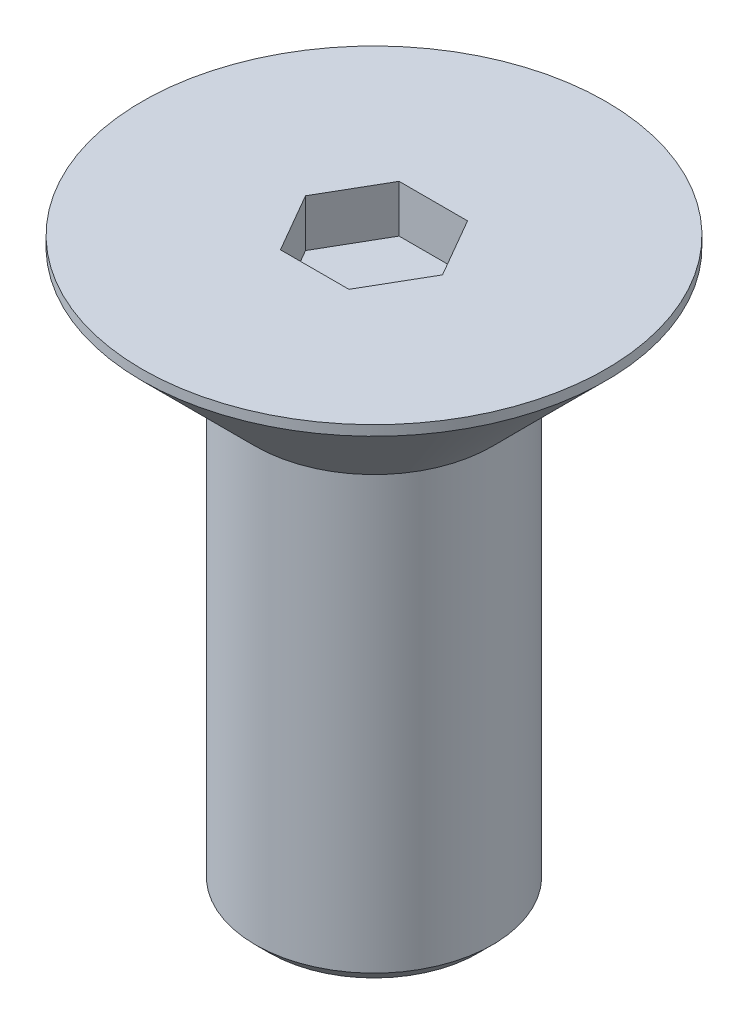
from build123d import *

# Parameters (mm, degrees)
CHAFL_N2_SIZE         = 0.3
CHAFL_N2_SIZE2        = 0.212132034
CHAFL_N3_SIZE         = 0.3
CORTAR_EXTRUIR2_DEPTH = 1


with BuildPart() as part:
    # Croquis1 → Revolución1 (revolve)
    with BuildSketch(Plane.XY, mode=Mode.PRIVATE) as revoluci_n1_sk:
        Polygon((0, 0), (5.1, 0), (2.5, -2.6), (2.5, -12), (0, -12), align=None)
    revolve(revoluci_n1_sk.sketch.rotate(Axis((0, 0, 0), (0, -1, 0)), 90), axis=Axis((0, 0, 0), (0, -1, 0)))

    # Chaflán2
    chafl_n2_edges = [part.edges().sort_by_distance(p)[0] for p in [
        (0, 0, -5.1),
    ]]
    chafl_n2_side = [part.faces().sort_by_distance(p)[0] for p in [
        (0, -1.3, -3.8),
    ]]
    chamfer(chafl_n2_edges, length=CHAFL_N2_SIZE, length2=CHAFL_N2_SIZE2, reference=chafl_n2_side[0])

    # Chaflán3
    chafl_n3_edges = [part.edges().sort_by_distance(p)[0] for p in [
        (0, -12, -2.5),
    ]]
    chamfer(chafl_n3_edges, length=CHAFL_N3_SIZE)

    # Croquis3 → Cortar-Extruir2 (cut)
    with BuildSketch(Plane(origin=(0, 0, 0), x_dir=(1, 0, 0), z_dir=(0, 1, 0))):
        Polygon((-0.721687836, 1.25), (-1.443375673, 0), (-0.721687836, -1.25), (0.721687836, -1.25), (1.443375673, 0), (0.721687836, 1.25), align=None)
    extrude(amount=-CORTAR_EXTRUIR2_DEPTH, mode=Mode.SUBTRACT)


solid = part.part
